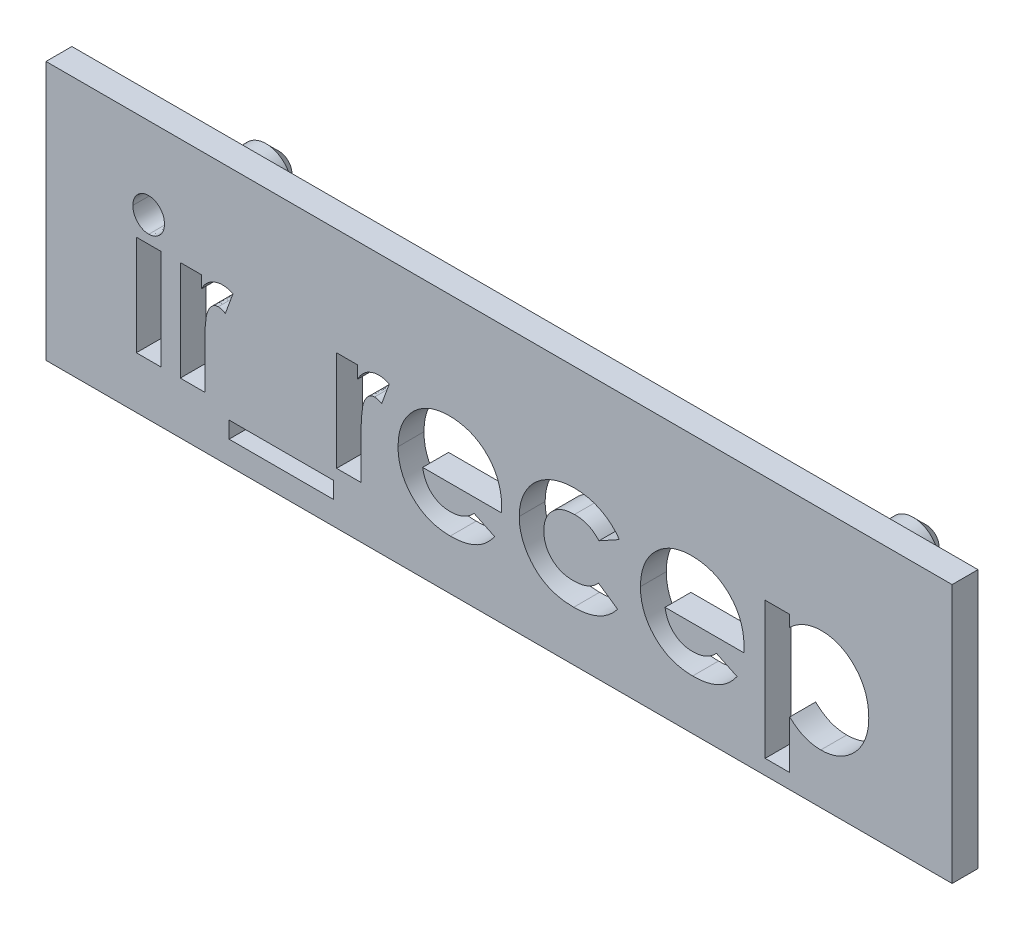
from build123d import *

# Parameters (mm, degrees)
ESQUISSE1_W             = 35
ESQUISSE1_H             = 10
BOSS_EXTRU_1_DEPTH      = 1
ESQUISSE2_R             = 1
BOSS_EXTRU_2_DEPTH      = 3
CHANFREIN1_SIZE         = 0.5
ESQUISSE3_W             = 0.949786325
ESQUISSE3_H             = 3.866987179
ESQUISSE3_W_2           = 3.731303419
ESQUISSE3_H_2           = 0.339209402
ENL_V_MAT_EXTRU_2_DEPTH = 1
ESQUISSE4_W             = 4.031303419
ESQUISSE4_H             = 0.639209402
ENL_V_MAT_EXTRU_3_DEPTH = 5


with BuildPart() as part:
    # Esquisse1 → Boss.-Extru.1 (new body)
    with BuildSketch(Plane.XY):
        with Locations((17.5, -5)):
            Rectangle(ESQUISSE1_W, ESQUISSE1_H)
    extrude(amount=BOSS_EXTRU_1_DEPTH)

    # Esquisse2 → Boss.-Extru.2 (add)
    with BuildSketch(Plane(origin=(0, 0, 0), x_dir=(-1, 0, 0), z_dir=(0, 0, -1))):
        with Locations(Location((-30, -3, 0), (0, 0, 180))):  # turned: the seam where the file's is
            Circle(ESQUISSE2_R)
        with Locations(Location((-5, -3, 0), (0, 0, 180))):  # turned: the seam where the file's is
            Circle(ESQUISSE2_R)
    extrude(amount=BOSS_EXTRU_2_DEPTH)

    # Chanfrein1
    chanfrein1_edges = [part.edges().sort_by_distance(p)[0] for p in [
        (29, -3, -3),
        (4, -3, -3),
    ]]
    chamfer(chanfrein1_edges, length=CHANFREIN1_SIZE)

    # Esquisse3 → Enlèv. mat.-Extru.2 (cut)
    with BuildSketch(Plane.XY.offset(1)):
        with BuildLine():
            add(Edge.make_bspline(
                [(3.963424813, -2.504807692), (4.004360597, -2.506816157), (4.084741953, -2.51075997), (4.199899183, -2.549203379), (4.305590182, -2.609539161), (4.399023956, -2.692321292), (4.476733433, -2.791178297), (4.536106359, -2.901855287), (4.569180543, -3.024481827), (4.573774058, -3.109190958), (4.576121795, -3.152485644)],
                knots=[0, 0, 0, 0, 0.989868614, 1.943702388, 2.910836514, 3.924849579, 4.949916355, 5.946401046, 6.950409252, 8, 8, 8, 8], degree=3))
            add(Edge.make_bspline(
                [(4.576121795, -3.152485644), (4.573858056, -3.195461271), (4.569447052, -3.279201328), (4.535345136, -3.400163155), (4.478355233, -3.510786389), (4.400016358, -3.608175184), (4.307595528, -3.68962406), (4.204213959, -3.751055201), (4.090160268, -3.787360012), (4.011026189, -3.791633507), (3.970845019, -3.793803419)],
                knots=[0, 0, 0, 0, 1.05296456, 2.051751585, 3.055639087, 4.085634717, 5.099016424, 6.062201612, 7.016062274, 8, 8, 8, 8], degree=3))
            add(Edge.make_bspline(
                [(3.970845019, -3.793803419), (3.929551899, -3.791802134), (3.848471229, -3.787872533), (3.732369472, -3.749339175), (3.625268825, -3.689478577), (3.532240366, -3.605005079), (3.453640943, -3.50544562), (3.396861449, -3.392191974), (3.361344472, -3.268726916), (3.357128638, -3.182763185), (3.354967949, -3.138705262)],
                knots=[0, 0, 0, 0, 0.989065327, 1.942068821, 2.907541208, 3.917690034, 4.939857478, 5.938239964, 6.943311734, 8, 8, 8, 8], degree=3))
            add(Edge.make_bspline(
                [(3.354967949, -3.138705262), (3.357319369, -3.096459386), (3.361938395, -3.013473462), (3.395210697, -2.893573269), (3.453222204, -2.784756933), (3.530371931, -2.687709598), (3.622985043, -2.606471665), (3.728612594, -2.547968321), (3.842994812, -2.511112734), (3.92286698, -2.506931074), (3.963424813, -2.504807692)],
                knots=[0, 0, 0, 0, 1.038616768, 2.040212704, 3.031499824, 4.052181184, 5.074969369, 6.039807101, 7.004644834, 8, 8, 8, 8], degree=3))
        make_face()
        with Locations((3.965544872, -6.066506411)):
            Rectangle(ESQUISSE3_W, ESQUISSE3_H)
        with BuildLine():
            Line((5.186698718, -4.133012821), (6.000801282, -4.133012821))
            Line((6.000801282, -4.133012821), (6.000801282, -4.608966012))
            add(Edge.make_bspline(
                [(6.000801282, -4.608966012), (6.023830681, -4.566667921), (6.068842596, -4.483994547), (6.151533259, -4.373021915), (6.246531642, -4.27956386), (6.350424159, -4.201665623), (6.463525688, -4.140951595), (6.582807572, -4.097685197), (6.707249356, -4.069568033), (6.792139323, -4.066647192), (6.835044404, -4.06517094)],
                knots=[0, 0, 0, 0, 1.09866127, 2.147379032, 3.14564304, 4.131443017, 5.102343063, 6.064490016, 7.021754664, 8, 8, 8, 8], degree=3))
            add(Edge.make_bspline(
                [(6.835044404, -4.06517094), (6.866198847, -4.066629785), (6.929640418, -4.069600514), (7.026334298, -4.086869409), (7.124423302, -4.118094854), (7.188974319, -4.146209218), (7.221955128, -4.160573584)],
                knots=[0, 0, 0, 0, 0.931404136, 1.896671404, 2.925354185, 4, 4, 4, 4], degree=3))
            Line((7.221955128, -4.160573584), (6.92726696, -4.965135884))
            add(Edge.make_bspline(
                [(6.92726696, -4.965135884), (6.900926046, -4.952409228), (6.851415268, -4.928488014), (6.779534215, -4.900258516), (6.714299178, -4.883034257), (6.672941362, -4.880464246), (6.65377938, -4.879273504)],
                knots=[0, 0, 0, 0, 1.214386998, 2.282580073, 3.20428172, 4, 4, 4, 4], degree=3))
            add(Edge.make_bspline(
                [(6.65377938, -4.879273504), (6.635686743, -4.880062553), (6.600095407, -4.881614748), (6.547563592, -4.894916529), (6.498089562, -4.917855038), (6.449289164, -4.947241545), (6.405012211, -4.988090988), (6.360762607, -5.03538147), (6.321767486, -5.093767862), (6.280616325, -5.15875488), (6.245577582, -5.238298932), (6.215532939, -5.333258138), (6.188762921, -5.444731242), (6.170341494, -5.57331011), (6.152536445, -5.717750521), (6.141938443, -5.879112649), (6.134039617, -6.056886251), (6.133556657, -6.180978642), (6.133304955, -6.245651376)],
                knots=[0, 0, 0, 0, 0.544232178, 1.070598461, 1.618251235, 2.182094276, 2.777567932, 3.425210017, 4.127676488, 4.886675562, 5.738955394, 6.734782583, 7.883056018, 9.186093582, 10.642914445, 12.264202625, 14.053029461, 16, 16, 16, 16], degree=3))
            Line((6.133304955, -6.245651376), (6.136485043, -6.434336605))
            Line((6.136485043, -6.434336605), (6.136485043, -8))
            Line((6.136485043, -8), (5.186698718, -8))
            Line((5.186698718, -8), (5.186698718, -4.133012821))
        make_face()
        with Locations((9.087606838, -8.780181624)):
            Rectangle(ESQUISSE3_W_2, ESQUISSE3_H_2)
        with BuildLine():
            Line((11.224626068, -4.133012821), (12.038728632, -4.133012821))
            Line((12.038728632, -4.133012821), (12.038728632, -4.608966012))
            add(Edge.make_bspline(
                [(12.038728632, -4.608966012), (12.061758031, -4.566667921), (12.106769946, -4.483994547), (12.189460609, -4.373021915), (12.284458992, -4.27956386), (12.38835151, -4.201665623), (12.501453039, -4.140951595), (12.620734923, -4.097685197), (12.745176707, -4.069568033), (12.830066673, -4.066647192), (12.872971755, -4.06517094)],
                knots=[0, 0, 0, 0, 1.09866127, 2.147379032, 3.14564304, 4.131443017, 5.102343063, 6.064490016, 7.021754664, 8, 8, 8, 8], degree=3))
            add(Edge.make_bspline(
                [(12.872971755, -4.06517094), (12.904126198, -4.066629785), (12.967567768, -4.069600514), (13.064261649, -4.086869409), (13.162350652, -4.118094854), (13.226901669, -4.146209218), (13.259882479, -4.160573584)],
                knots=[0, 0, 0, 0, 0.931404136, 1.896671404, 2.925354185, 4, 4, 4, 4], degree=3))
            Line((13.259882479, -4.160573584), (12.965194311, -4.965135884))
            add(Edge.make_bspline(
                [(12.965194311, -4.965135884), (12.938853397, -4.952409228), (12.889342618, -4.928488014), (12.817461565, -4.900258516), (12.752226529, -4.883034257), (12.710868713, -4.880464246), (12.691706731, -4.879273504)],
                knots=[0, 0, 0, 0, 1.214386998, 2.282580073, 3.20428172, 4, 4, 4, 4], degree=3))
            add(Edge.make_bspline(
                [(12.691706731, -4.879273504), (12.673614093, -4.880062553), (12.638022758, -4.881614748), (12.585490943, -4.894916529), (12.536016912, -4.917855038), (12.487216515, -4.947241545), (12.442939562, -4.988090988), (12.398689957, -5.03538147), (12.359694836, -5.093767862), (12.318543675, -5.15875488), (12.283504933, -5.238298932), (12.25346029, -5.333258138), (12.226690272, -5.444731242), (12.208268844, -5.57331011), (12.190463795, -5.717750521), (12.179865793, -5.879112649), (12.171966968, -6.056886251), (12.171484007, -6.180978642), (12.171232305, -6.245651376)],
                knots=[0, 0, 0, 0, 0.544232178, 1.070598461, 1.618251235, 2.182094276, 2.777567932, 3.425210017, 4.127676488, 4.886675562, 5.738955394, 6.734782583, 7.883056018, 9.186093582, 10.642914445, 12.264202625, 14.053029461, 16, 16, 16, 16], degree=3))
            Line((12.171232305, -6.245651376), (12.174412393, -6.434336605))
            Line((12.174412393, -6.434336605), (12.174412393, -8))
            Line((12.174412393, -8), (11.224626068, -8))
            Line((11.224626068, -8), (11.224626068, -4.133012821))
        make_face()
        with BuildLine():
            Line((17.598582732, -6.303952991), (14.548878205, -6.303952991))
            add(Edge.make_bspline(
                [(14.548878205, -6.303952991), (14.555096306, -6.339388828), (14.567315366, -6.409023042), (14.593849488, -6.510172781), (14.627711008, -6.605494587), (14.668291907, -6.695115884), (14.714907991, -6.779510462), (14.769281791, -6.858282479), (14.830723625, -6.931362358), (14.898878253, -6.998432487), (14.97260966, -7.058528775), (15.051560278, -7.111176923), (15.135811576, -7.154345184), (15.224397647, -7.190731548), (15.317980432, -7.219553234), (15.416697662, -7.239431004), (15.520287651, -7.251172875), (15.590856316, -7.252871202), (15.626928085, -7.253739316)],
                knots=[0, 0, 0, 0, 1.091296461, 2.144483647, 3.168565212, 4.157007626, 5.126487748, 6.090021542, 7.05641414, 8.019231907, 8.98705074, 9.938580405, 10.892824166, 11.854447369, 12.841318655, 13.858982407, 14.905600794, 16, 16, 16, 16], degree=3))
            add(Edge.make_bspline(
                [(15.626928085, -7.253739316), (15.670469158, -7.25258979), (15.756214355, -7.250326034), (15.881831706, -7.23024988), (16.003321983, -7.199925733), (16.119535459, -7.15483118), (16.231818286, -7.098696389), (16.338321943, -7.028759346), (16.440889925, -6.947063841), (16.503468481, -6.884092976), (16.535373264, -6.851988181)],
                knots=[0, 0, 0, 0, 1.021034703, 2.010718019, 2.977989445, 3.954245119, 4.929443971, 5.918328161, 6.938689359, 8, 8, 8, 8], degree=3))
            Line((16.535373264, -6.851988181), (17.330395299, -7.23041867))
            add(Edge.make_bspline(
                [(17.330395299, -7.23041867), (17.305364494, -7.2650074), (17.255766875, -7.333543698), (17.174800426, -7.42999197), (17.090306781, -7.51998212), (17.002222925, -7.602922269), (16.910437145, -7.678576072), (16.815204767, -7.747865128), (16.715134009, -7.808929053), (16.612225767, -7.864722083), (16.504352738, -7.91255319), (16.391813455, -7.953341869), (16.275084583, -7.990214488), (16.15269209, -8.018309404), (16.025655137, -8.04054911), (15.893669827, -8.056342248), (15.756753554, -8.066096912), (15.663692362, -8.067253315), (15.616327791, -8.06784188)],
                knots=[0, 0, 0, 0, 1.028154879, 2.037251081, 3.030720504, 4.000128189, 4.949298328, 5.894184978, 6.834267904, 7.770992897, 8.712077017, 9.673380525, 10.653304757, 11.658697181, 12.695551717, 13.758623199, 14.859225354, 16, 16, 16, 16], degree=3))
            add(Edge.make_bspline(
                [(15.616327791, -8.06784188), (15.543458177, -8.066356288), (15.400747238, -8.063446841), (15.192006692, -8.036443012), (14.993761069, -7.991667753), (14.805450594, -7.930802664), (14.627889269, -7.85044168), (14.460989219, -7.752153529), (14.303082873, -7.637822594), (14.158995153, -7.505049371), (14.027726989, -7.360533612), (13.912429196, -7.205333555), (13.815949644, -7.040533524), (13.736718695, -6.867224201), (13.67513765, -6.684961981), (13.630741288, -6.49366733), (13.603525786, -6.293431612), (13.600586377, -6.157048736), (13.59909188, -6.087706998)],
                knots=[0, 0, 0, 0, 1.103565453, 2.161269334, 3.182010356, 4.179077853, 5.15417608, 6.128274628, 7.109042802, 8.101804412, 9.090965879, 10.063106201, 11.02526161, 11.978650795, 12.945248442, 13.93468508, 14.949922959, 16, 16, 16, 16], degree=3))
            add(Edge.make_bspline(
                [(13.59909188, -6.087706998), (13.600601086, -6.016603197), (13.60357038, -5.876709662), (13.630506963, -5.67185041), (13.675260391, -5.476386975), (13.737021574, -5.290050184), (13.815050579, -5.112257255), (13.912757668, -4.944563662), (14.027669773, -4.786385588), (14.158465046, -4.638463007), (14.303163167, -4.504946716), (14.45691859, -4.385957019), (14.621458917, -4.286806905), (14.794923053, -4.206693674), (14.976201461, -4.141603697), (15.167389465, -4.098291753), (15.367032415, -4.069210375), (15.50350394, -4.066532162), (15.572866587, -4.06517094)],
                knots=[0, 0, 0, 0, 1.079208495, 2.12329425, 3.130605359, 4.119693003, 5.099659317, 6.073216462, 7.060498243, 8.06384408, 9.066070512, 10.045757761, 11.010926815, 11.975797609, 12.942977511, 13.929384301, 14.947594487, 16, 16, 16, 16], degree=3))
            add(Edge.make_bspline(
                [(15.572866587, -4.06517094), (15.646085295, -4.06667958), (15.789842684, -4.06964164), (16.000037044, -4.096426204), (16.199598994, -4.141474498), (16.389378779, -4.201813297), (16.566952834, -4.284204284), (16.736222999, -4.380073719), (16.893129216, -4.496876004), (17.039343937, -4.628999478), (17.171332606, -4.775585892), (17.286705327, -4.934823635), (17.384873313, -5.105158639), (17.46443944, -5.287281648), (17.525957253, -5.480645912), (17.570394711, -5.68500031), (17.597402624, -5.901122106), (17.600287337, -6.049113087), (17.601762821, -6.124808026)],
                knots=[0, 0, 0, 0, 1.080001299, 2.120471247, 3.119684163, 4.095710327, 5.052285597, 6.002875087, 6.961153713, 7.931888285, 8.906493152, 9.865905668, 10.82813294, 11.801621613, 12.7925306, 13.817193356, 14.883530496, 16, 16, 16, 16], degree=3))
            Line((17.601762821, -6.124808026), (17.598582732, -6.303952991))
        make_face()
        with BuildLine():
            Line((22.147168803, -4.921674679), (21.360627003, -5.354166667))
            add(Edge.make_bspline(
                [(21.360627003, -5.354166667), (21.324574794, -5.318063555), (21.255273383, -5.248664299), (21.144143002, -5.16081585), (21.034998375, -5.088079778), (20.92333992, -5.034404293), (20.808169544, -4.993981508), (20.685333191, -4.96720861), (20.553397145, -4.949579608), (20.462136832, -4.947953728), (20.415080796, -4.947115385)],
                knots=[0, 0, 0, 0, 1.150764855, 2.212059359, 3.192108068, 4.105322427, 5.000809612, 5.941206042, 6.938435785, 8, 8, 8, 8], degree=3))
            add(Edge.make_bspline(
                [(20.415080796, -4.947115385), (20.371927163, -4.948157704), (20.287479123, -4.950197436), (20.164087135, -4.965432834), (20.046815695, -4.989361835), (19.935875311, -5.024370047), (19.831463579, -5.0706178), (19.73271706, -5.12534506), (19.640595309, -5.190689399), (19.556400493, -5.265721963), (19.480399873, -5.348331153), (19.412603443, -5.436437405), (19.357062156, -5.531347754), (19.309043269, -5.630831462), (19.273739197, -5.736757056), (19.247909879, -5.848163371), (19.233187409, -5.965055344), (19.231054383, -6.044912531), (19.229967949, -6.085586939)],
                knots=[0, 0, 0, 0, 1.121765476, 2.195200973, 3.227634963, 4.230038321, 5.213228299, 6.192116585, 7.160777141, 8.14345191, 9.118668839, 10.075979138, 11.027630062, 11.972829041, 12.943187208, 13.923755399, 14.94248691, 16, 16, 16, 16], degree=3))
            add(Edge.make_bspline(
                [(19.229967949, -6.085586939), (19.23111586, -6.125199879), (19.233357238, -6.202546952), (19.247127508, -6.316188233), (19.271033216, -6.424369883), (19.306876696, -6.526519978), (19.349839113, -6.623580196), (19.403792045, -6.714778598), (19.46723772, -6.800513425), (19.540510155, -6.880039516), (19.621677418, -6.951563477), (19.709182093, -7.01472654), (19.8027631, -7.068277132), (19.903510566, -7.110302311), (20.009781903, -7.144544041), (20.122286797, -7.168925493), (20.240905523, -7.182458885), (20.321764905, -7.184733534), (20.363139356, -7.185897436)],
                knots=[0, 0, 0, 0, 1.070556293, 2.090336998, 3.088792742, 4.058148387, 5.011235098, 5.952916408, 6.915475435, 7.888633318, 8.869583867, 9.83422472, 10.800707077, 11.776204622, 12.778807041, 13.814557445, 14.881744048, 16, 16, 16, 16], degree=3))
            add(Edge.make_bspline(
                [(20.363139356, -7.185897436), (20.414081222, -7.184731737), (20.513512341, -7.182456462), (20.658056332, -7.163158313), (20.79407025, -7.131245961), (20.921568518, -7.08707673), (21.040372765, -7.029324638), (21.150177731, -6.958784767), (21.252112208, -6.875977477), (21.31155478, -6.811419049), (21.341546474, -6.778846154)],
                knots=[0, 0, 0, 0, 1.116373375, 2.178998604, 3.189797796, 4.174590301, 5.13072713, 6.078291395, 7.030403691, 8, 8, 8, 8], degree=3))
            Line((21.341546474, -6.778846154), (22.079326923, -7.285540198))
            add(Edge.make_bspline(
                [(22.079326923, -7.285540198), (22.028187526, -7.348064577), (21.927267815, -7.471451686), (21.751190903, -7.630493165), (21.561678964, -7.767145135), (21.354920503, -7.876219005), (21.133926605, -7.962973325), (20.896970417, -8.024300017), (20.644452733, -8.060400427), (20.471028031, -8.065321747), (20.382219885, -8.06784188)],
                knots=[0, 0, 0, 0, 0.997876357, 1.969233105, 2.924898516, 3.881013542, 4.852507933, 5.855329832, 6.901747111, 8, 8, 8, 8], degree=3))
            add(Edge.make_bspline(
                [(20.382219885, -8.06784188), (20.302287046, -8.06599407), (20.146169399, -8.062385093), (19.918631806, -8.034747141), (19.704620884, -7.988194771), (19.503696381, -7.923543097), (19.316041481, -7.839794971), (19.142264766, -7.735916003), (18.981194114, -7.614795726), (18.835735888, -7.475861975), (18.705953774, -7.324631087), (18.592653521, -7.165360916), (18.49466628, -7.000905122), (18.417795385, -6.828526399), (18.354970677, -6.650911564), (18.312540841, -6.465937483), (18.284555751, -6.275127813), (18.281651402, -6.145756539), (18.280181624, -6.080286792)],
                knots=[0, 0, 0, 0, 1.183377041, 2.311265848, 3.387807024, 4.421911742, 5.431260577, 6.423665966, 7.413571885, 8.409103097, 9.395976332, 10.359992013, 11.300391101, 12.225292883, 13.150239058, 14.085544813, 15.031169026, 16, 16, 16, 16], degree=3))
            add(Edge.make_bspline(
                [(18.280181624, -6.080286792), (18.280968995, -6.034673464), (18.282528534, -5.944327486), (18.295842067, -5.810153634), (18.316553451, -5.678256658), (18.347680216, -5.549562407), (18.385960642, -5.423446502), (18.432495683, -5.299934295), (18.489120854, -5.17966313), (18.552286403, -5.061609908), (18.624277538, -4.94889106), (18.702818373, -4.841556334), (18.787798251, -4.740263106), (18.880215471, -4.645955402), (18.97942564, -4.557958412), (19.083986501, -4.474486841), (19.197281592, -4.399845508), (19.315372338, -4.329668868), (19.439275969, -4.267198143), (19.567568382, -4.213277671), (19.699258164, -4.167464453), (19.834660967, -4.130629702), (19.973195617, -4.100271113), (20.116094826, -4.081004305), (20.262176344, -4.067462079), (20.360987139, -4.065939258), (20.410840678, -4.06517094)],
                knots=[0, 0, 0, 0, 1.00272354, 1.986087015, 2.96193297, 3.936200312, 4.894695956, 5.858592327, 6.835334787, 7.815655071, 8.800643866, 9.773423113, 10.738352213, 11.705312252, 12.673769326, 13.65298065, 14.64420052, 15.654211674, 16.672258995, 17.692438602, 18.712115155, 19.735602823, 20.776372304, 21.827874031, 22.90408564, 24, 24, 24, 24], degree=3))
            add(Edge.make_bspline(
                [(20.410840678, -4.06517094), (20.457148221, -4.065694486), (20.548476486, -4.06672703), (20.68334769, -4.07752371), (20.814539881, -4.095862345), (20.942276324, -4.120123587), (21.066944954, -4.150187491), (21.186874879, -4.190261668), (21.303705745, -4.235744349), (21.454185134, -4.304418449), (21.631572791, -4.406925659), (21.826296915, -4.553943595), (21.999917043, -4.725933137), (22.097823997, -4.856080703), (22.147168803, -4.921674679)],
                knots=[0, 0, 0, 0, 0.826738014, 1.630502179, 2.413926014, 3.191023582, 3.95155221, 4.701751672, 5.446919844, 6.189438973, 7.653650558, 9.094719814, 10.535747635, 12, 12, 12, 12], degree=3))
        make_face()
        with BuildLine():
            Line((26.96076222, -6.303952991), (23.911057692, -6.303952991))
            add(Edge.make_bspline(
                [(23.911057692, -6.303952991), (23.917275794, -6.339388828), (23.929494853, -6.409023042), (23.956028975, -6.510172781), (23.989890495, -6.605494587), (24.030471394, -6.695115884), (24.077087478, -6.779510462), (24.131461278, -6.858282479), (24.192903113, -6.931362358), (24.26105774, -6.998432487), (24.334789148, -7.058528775), (24.413739765, -7.111176923), (24.497991063, -7.154345184), (24.586577134, -7.190731548), (24.680159919, -7.219553234), (24.778877149, -7.239431004), (24.882467138, -7.251172875), (24.953035803, -7.252871202), (24.989107572, -7.253739316)],
                knots=[0, 0, 0, 0, 1.091296461, 2.144483647, 3.168565212, 4.157007626, 5.126487748, 6.090021542, 7.05641414, 8.019231907, 8.98705074, 9.938580405, 10.892824166, 11.854447369, 12.841318655, 13.858982407, 14.905600794, 16, 16, 16, 16], degree=3))
            add(Edge.make_bspline(
                [(24.989107572, -7.253739316), (25.032648646, -7.25258979), (25.118393842, -7.250326034), (25.244011193, -7.23024988), (25.36550147, -7.199925733), (25.481714946, -7.15483118), (25.593997773, -7.098696389), (25.70050143, -7.028759346), (25.803069412, -6.947063841), (25.865647968, -6.884092976), (25.897552751, -6.851988181)],
                knots=[0, 0, 0, 0, 1.021034703, 2.010718019, 2.977989445, 3.954245119, 4.929443971, 5.918328161, 6.938689359, 8, 8, 8, 8], degree=3))
            Line((25.897552751, -6.851988181), (26.692574786, -7.23041867))
            add(Edge.make_bspline(
                [(26.692574786, -7.23041867), (26.667543982, -7.2650074), (26.617946362, -7.333543698), (26.536979914, -7.42999197), (26.452486268, -7.51998212), (26.364402412, -7.602922269), (26.272616632, -7.678576072), (26.177384254, -7.747865128), (26.077313496, -7.808929053), (25.974405254, -7.864722083), (25.866532226, -7.91255319), (25.753992942, -7.953341869), (25.63726407, -7.990214488), (25.514871578, -8.018309404), (25.387834625, -8.04054911), (25.255849314, -8.056342248), (25.118933042, -8.066096912), (25.025871849, -8.067253315), (24.978507278, -8.06784188)],
                knots=[0, 0, 0, 0, 1.028154879, 2.037251081, 3.030720504, 4.000128189, 4.949298328, 5.894184978, 6.834267904, 7.770992897, 8.712077017, 9.673380525, 10.653304757, 11.658697181, 12.695551717, 13.758623199, 14.859225354, 16, 16, 16, 16], degree=3))
            add(Edge.make_bspline(
                [(24.978507278, -8.06784188), (24.905637664, -8.066356288), (24.762926726, -8.063446841), (24.554186179, -8.036443012), (24.355940557, -7.991667753), (24.167630081, -7.930802664), (23.990068756, -7.85044168), (23.823168706, -7.752153529), (23.665262361, -7.637822594), (23.521174641, -7.505049371), (23.389906476, -7.360533612), (23.274608683, -7.205333555), (23.178129131, -7.040533524), (23.098898183, -6.867224201), (23.037317137, -6.684961981), (22.992920775, -6.49366733), (22.965705274, -6.293431612), (22.962765864, -6.157048736), (22.961271368, -6.087706998)],
                knots=[0, 0, 0, 0, 1.103565453, 2.161269334, 3.182010356, 4.179077853, 5.15417608, 6.128274628, 7.109042802, 8.101804412, 9.090965879, 10.063106201, 11.02526161, 11.978650795, 12.945248442, 13.93468508, 14.949922959, 16, 16, 16, 16], degree=3))
            add(Edge.make_bspline(
                [(22.961271368, -6.087706998), (22.962780573, -6.016603197), (22.965749868, -5.876709662), (22.99268645, -5.67185041), (23.037439878, -5.476386975), (23.099201061, -5.290050184), (23.177230066, -5.112257255), (23.274937155, -4.944563662), (23.38984926, -4.786385588), (23.520644534, -4.638463007), (23.665342654, -4.504946716), (23.819098077, -4.385957019), (23.983638404, -4.286806905), (24.15710254, -4.206693674), (24.338380948, -4.141603697), (24.529568952, -4.098291753), (24.729211902, -4.069210375), (24.865683427, -4.066532162), (24.935046074, -4.06517094)],
                knots=[0, 0, 0, 0, 1.079208495, 2.12329425, 3.130605359, 4.119693003, 5.099659317, 6.073216462, 7.060498243, 8.06384408, 9.066070512, 10.045757761, 11.010926815, 11.975797609, 12.942977511, 13.929384301, 14.947594487, 16, 16, 16, 16], degree=3))
            add(Edge.make_bspline(
                [(24.935046074, -4.06517094), (25.008264783, -4.06667958), (25.152022171, -4.06964164), (25.362216531, -4.096426204), (25.561778481, -4.141474498), (25.751558266, -4.201813297), (25.929132321, -4.284204284), (26.098402486, -4.380073719), (26.255308703, -4.496876004), (26.401523425, -4.628999478), (26.533512093, -4.775585892), (26.648884814, -4.934823635), (26.7470528, -5.105158639), (26.826618927, -5.287281648), (26.88813674, -5.480645912), (26.932574199, -5.68500031), (26.959582111, -5.901122106), (26.962466824, -6.049113087), (26.963942308, -6.124808026)],
                knots=[0, 0, 0, 0, 1.080001299, 2.120471247, 3.119684163, 4.095710327, 5.052285597, 6.002875087, 6.961153713, 7.931888285, 8.906493152, 9.865905668, 10.82813294, 11.801621613, 12.7925306, 13.817193356, 14.883530496, 16, 16, 16, 16], degree=3))
            Line((26.963942308, -6.124808026), (26.96076222, -6.303952991))
        make_face()
        with BuildLine():
            Line((28.727831197, -4.133012821), (28.727831197, -4.568684896))
            add(Edge.make_bspline(
                [(28.727831197, -4.568684896), (28.771925602, -4.528171753), (28.858522465, -4.448608122), (29.000304956, -4.346742923), (29.146007868, -4.259256524), (29.298308338, -4.188889417), (29.455116244, -4.133445707), (29.617836677, -4.09448843), (29.785273308, -4.068795061), (29.899068263, -4.066385185), (29.956405248, -4.06517094)],
                knots=[0, 0, 0, 0, 1.054376801, 2.070687235, 3.070225973, 4.045259405, 5.022040922, 5.996139433, 6.99033025, 8, 8, 8, 8], degree=3))
            add(Edge.make_bspline(
                [(29.956405248, -4.06517094), (30.0186912, -4.066662846), (30.141374313, -4.069601416), (30.321879172, -4.097037187), (30.494860487, -4.141385223), (30.66097788, -4.203307169), (30.819346297, -4.283702473), (30.97174512, -4.379960671), (31.115546052, -4.496053903), (31.250818999, -4.627548954), (31.375949846, -4.771677298), (31.484790637, -4.928375398), (31.575450793, -5.095580805), (31.652289729, -5.271316802), (31.708369871, -5.458497913), (31.751591765, -5.654613228), (31.77567743, -5.861321926), (31.779014582, -6.002139788), (31.780715812, -6.073926616)],
                knots=[0, 0, 0, 0, 0.985987466, 1.942075377, 2.884088208, 3.810275091, 4.743821533, 5.692411115, 6.659945104, 7.665215984, 8.677116751, 9.678438675, 10.680260931, 11.685531812, 12.710472044, 13.769734641, 14.863044265, 16, 16, 16, 16], degree=3))
            add(Edge.make_bspline(
                [(31.780715812, -6.073926616), (31.779105711, -6.14325599), (31.775931848, -6.279919471), (31.750289034, -6.480552708), (31.706826611, -6.672214326), (31.645857639, -6.854973348), (31.56834965, -7.029407327), (31.4737458, -7.195396066), (31.361494244, -7.352359771), (31.233161749, -7.498183983), (31.092939848, -7.630238647), (30.946838678, -7.748717936), (30.791948384, -7.845802422), (30.632140878, -7.927797708), (30.464898585, -7.990497917), (30.291363844, -8.03442646), (30.111811491, -8.063795417), (29.989737761, -8.066479625), (29.927784455, -8.06784188)],
                knots=[0, 0, 0, 0, 1.098553145, 2.165490463, 3.199345634, 4.208780719, 5.21409072, 6.219899742, 7.23156933, 8.267303578, 9.293302409, 10.281606823, 11.243293419, 12.184993323, 13.124258899, 14.066907486, 15.018941492, 16, 16, 16, 16], degree=3))
            add(Edge.make_bspline(
                [(29.927784455, -8.06784188), (29.87257689, -8.066502987), (29.763821308, -8.063865449), (29.603898756, -8.040348446), (29.449411755, -8.005222037), (29.300155949, -7.952352875), (29.154453437, -7.882195943), (29.009822724, -7.794828168), (28.865929368, -7.688093559), (28.774851563, -7.605769171), (28.727831197, -7.563267895)],
                knots=[0, 0, 0, 0, 0.990856396, 1.951927477, 2.896945079, 3.83213376, 4.788585491, 5.796263726, 6.862286081, 8, 8, 8, 8], degree=3))
            Line((28.727831197, -7.563267895), (28.727831197, -9.424679487))
            Line((28.727831197, -9.424679487), (27.778044872, -9.424679487))
            Line((27.778044872, -9.424679487), (27.778044872, -4.133012821))
            Line((27.778044872, -4.133012821), (28.727831197, -4.133012821))
        make_face()
    extrude(amount=-ENL_V_MAT_EXTRU_2_DEPTH, mode=Mode.SUBTRACT)

    # Esquisse4 → Enlèv. mat.-Extru.3 (cut, through all)
    with BuildSketch(Plane.XY.offset(1)):
        with Locations((9.087606838, -8.780181624)):
            Rectangle(ESQUISSE4_W, ESQUISSE4_H)
    extrude(amount=-ENL_V_MAT_EXTRU_3_DEPTH, mode=Mode.SUBTRACT)


solid = part.part
